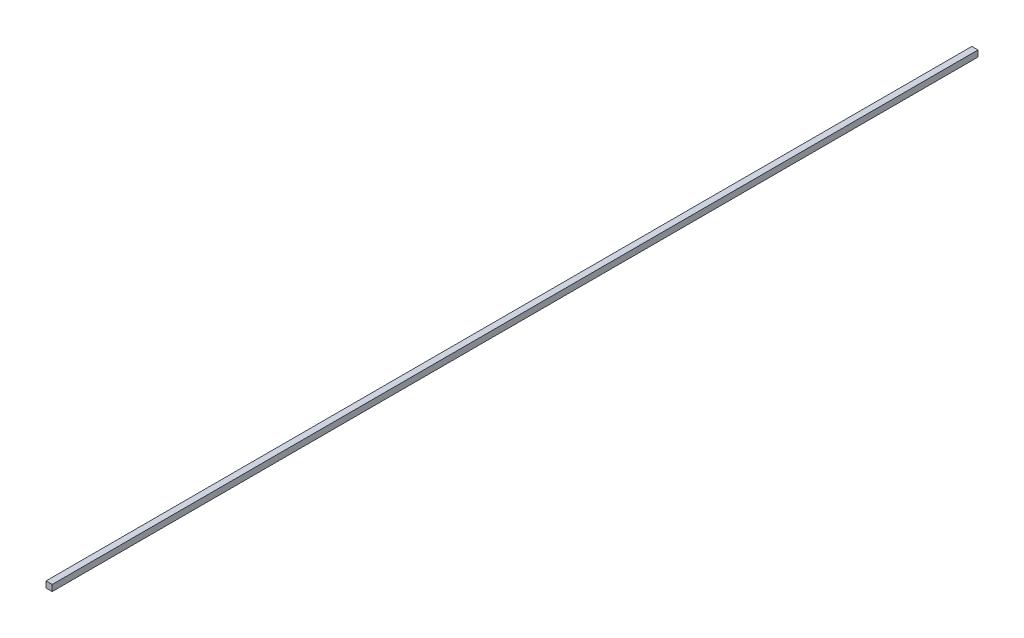
from build123d import *

# Parameters (mm, degrees)
SKETCH_1_W      = 4
SKETCH_1_H      = 4
EXTRUDE_1_DEPTH = 600


with BuildPart() as part:
    # ｽｹｯﾁ1 → ﾎﾞｽ - 押し出し1 (new body)
    with BuildSketch(Plane.XY):
        Rectangle(SKETCH_1_W, SKETCH_1_H)
    extrude(amount=EXTRUDE_1_DEPTH)


solid = part.part
